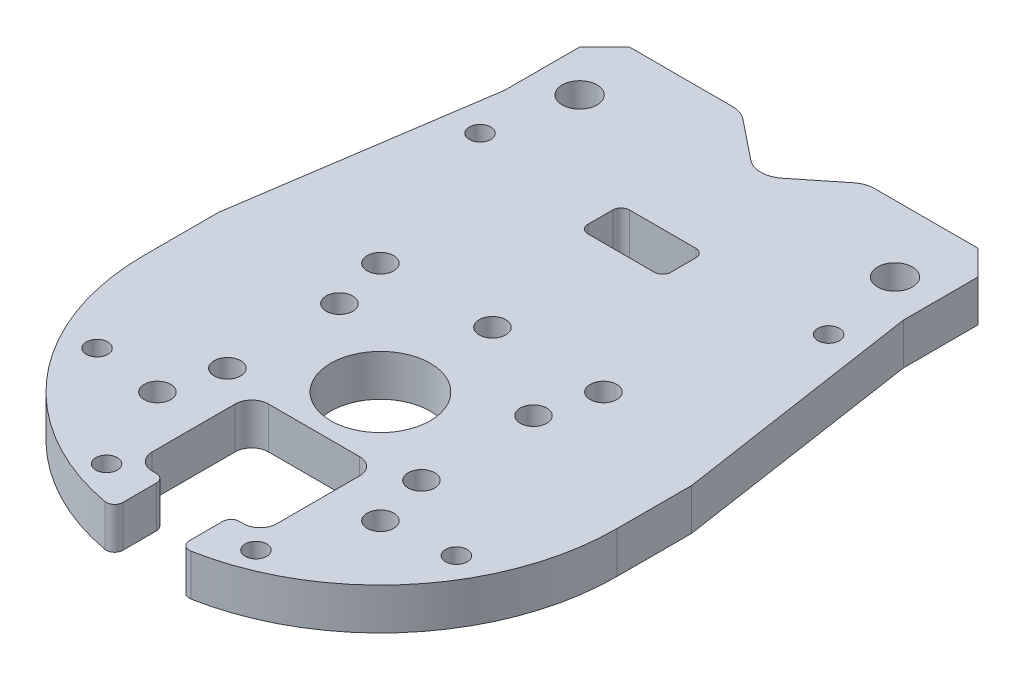
from build123d import *

# Parameters (mm, degrees)
EXTRUDE_1_DEPTH        = 5
HOLE_WIZARD_M5_1_D     = 4.2
HOLE_WIZARD_M5_1_DEPTH = 5
SKETCH_4_R             = 1.6
CUT_EXTRUDE_1_DEPTH    = 10
SKETCH_5_R             = 1.6
CUT_EXTRUDE_2_DEPTH    = 10
SKETCH_6_R             = 6
CUT_EXTRUDE_3_DEPTH    = 10
CHAMFER_1_SIZE         = 2
CUT_EXTRUDE_4_DEPTH    = 6
CHAMFER_2_SIZE         = 3
SKETCH_8_R             = 1.3
CUT_EXTRUDE_5_DEPTH    = 6
SKETCH_9_R             = 1.3
CUT_EXTRUDE_6_DEPTH    = 6
CUT_EXTRUDE_8_DEPTH    = 10
FILLET_1_R             = 3
SKETCH_12_W            = 15
SKETCH_12_H            = 14
CUT_EXTRUDE_9_DEPTH    = 10
FILLET_2_R             = 2
SKETCH_13_W            = 8
SKETCH_13_H            = 6.5
CUT_EXTRUDE_10_DEPTH   = 10
FILLET_3_R             = 1
SKETCH_14_R            = 1.3
CUT_EXTRUDE_11_DEPTH   = 10
SKETCH_15_W            = 10
SKETCH_15_H            = 5
CUT_EXTRUDE_12_DEPTH   = 10
FILLET_4_R             = 1


with BuildPart() as part:
    # 草图1 → 凸台-拉伸1 (new body)
    with BuildSketch(Plane(origin=(0, 0, 0), x_dir=(1, 0, 0), z_dir=(0, 1, 0))):
        with BuildLine():
            Line((-28.5, 0), (28.5, 0))
            Line((28.5, 0), (28.5, -51))
            ThreePointArc((28.5, -51), (0, -79.5), (-28.5, -51))
            Line((-28.5, -51), (-28.5, 0))
        make_face()
    extrude(amount=EXTRUDE_1_DEPTH)

    # M5 螺纹孔1
    with Locations(Plane(origin=(19, 5, 8), x_dir=(0, 0, 1), z_dir=(0, 1, 0))):
        with Locations((0, 0), (0, -38)):
            Hole(HOLE_WIZARD_M5_1_D / 2, depth=HOLE_WIZARD_M5_1_DEPTH)

    # 草图4 → 切除-拉伸1 (cut)
    with BuildSketch(Plane.XZ):
        with Locations((-13.435028843, 64.435028843)):
            Circle(SKETCH_4_R)
        with Locations((13.435028843, 64.435028843)):
            Circle(SKETCH_4_R)
        with Locations((13.435028843, 37.564971157)):
            Circle(SKETCH_4_R)
        with Locations((-13.435028843, 37.564971157)):
            Circle(SKETCH_4_R)
    extrude(amount=-CUT_EXTRUDE_1_DEPTH, mode=Mode.SUBTRACT)

    # 草图5 → 切除-拉伸2 (cut)
    with BuildSketch(Plane.XZ):
        with Locations((0, 64.5)):
            Circle(SKETCH_5_R)
        with Locations((11.691342951, 57.75)):
            Circle(SKETCH_5_R)
        with Locations((11.691342951, 44.25)):
            Circle(SKETCH_5_R)
        with Locations((0, 37.5)):
            Circle(SKETCH_5_R)
        with Locations((-11.691342951, 44.25)):
            Circle(SKETCH_5_R)
        with Locations((-11.691342951, 57.75)):
            Circle(SKETCH_5_R)
    extrude(amount=-CUT_EXTRUDE_2_DEPTH, mode=Mode.SUBTRACT)

    # 草图6 → 切除-拉伸3 (cut)
    with BuildSketch(Plane.XZ):
        with Locations((0, 51)):
            Circle(SKETCH_6_R)
    extrude(amount=-CUT_EXTRUDE_3_DEPTH, mode=Mode.SUBTRACT)

    # 倒角1
    chamfer_1_edges = [part.edges().sort_by_distance(p)[0] for p in [
        (-28.5, 2.5, 0),
        (28.5, 2.5, 0),
    ]]
    chamfer(chamfer_1_edges, length=CHAMFER_1_SIZE)

    # 草图7 → 切除-拉伸4 (cut, through all)
    with BuildSketch(Plane(origin=(0, 5, 0), x_dir=(1, 0, 0), z_dir=(0, 1, 0))):
        Polygon((-24, 0), (-24, -12), (-28.5, -42), (-28.5, -2), (-26.5, 0), align=None)
        Polygon((28.5, -2), (28.5, -42), (24, -12), (24, 0), (26.5, 0), align=None)
    extrude(amount=-CUT_EXTRUDE_4_DEPTH, mode=Mode.SUBTRACT)

    # 倒角2
    chamfer_2_edges = [part.edges().sort_by_distance(p)[0] for p in [
        (-24, 2.5, 0),
        (24, 2.5, 0),
    ]]
    chamfer(chamfer_2_edges, length=CHAMFER_2_SIZE)

    # 草图8 → 切除-拉伸5 (cut, through all)
    with BuildSketch(Plane(origin=(0, 5, 0), x_dir=(1, 0, 0), z_dir=(0, 1, 0))):
        with Locations((-21.650635095, -63.5)):
            Circle(SKETCH_8_R)
        with Locations((21.650635095, -63.5)):
            Circle(SKETCH_8_R)
    extrude(amount=-CUT_EXTRUDE_5_DEPTH, mode=Mode.SUBTRACT)

    # 草图9 → 切除-拉伸6 (cut, through all)
    with BuildSketch(Plane(origin=(0, 5, 0), x_dir=(1, 0, 0), z_dir=(0, 1, 0))):
        with Locations((-21, -18)):
            Circle(SKETCH_9_R)
        with Locations((21, -18)):
            Circle(SKETCH_9_R)
    extrude(amount=-CUT_EXTRUDE_6_DEPTH, mode=Mode.SUBTRACT)

    # 草图11 → 切除-拉伸8 (cut)
    with BuildSketch(Plane(origin=(0, 5, 0), x_dir=(1, 0, 0), z_dir=(0, 1, 0))):
        Polygon((-7.5, 0), (0, -6), (7.5, 0), align=None)
    extrude(amount=-CUT_EXTRUDE_8_DEPTH, mode=Mode.SUBTRACT)

    # 圆角1
    fillet_1_edges = [part.edges().sort_by_distance(p)[0] for p in [
        (-7.5, 2.5, 0),
        (7.5, 2.5, 0),
        (0, 2.5, 6),
    ]]
    fillet(fillet_1_edges, radius=FILLET_1_R)

    # 草图12 → 切除-拉伸9 (cut)
    with BuildSketch(Plane(origin=(0, 5, 0), x_dir=(1, 0, 0), z_dir=(0, 1, 0))):
        with Locations((0, -66)):
            Rectangle(SKETCH_12_W, SKETCH_12_H)
    extrude(amount=-CUT_EXTRUDE_9_DEPTH, mode=Mode.SUBTRACT)

    # 圆角2
    fillet_2_edges = [part.edges().sort_by_distance(p)[0] for p in [
        (-7.5, 2.5, 73),
        (-7.5, 2.5, 59),
        (7.5, 2.5, 59),
        (7.5, 2.5, 73),
    ]]
    fillet(fillet_2_edges, radius=FILLET_2_R)

    # 草图13 → 切除-拉伸10 (cut)
    with BuildSketch(Plane.XZ):
        with Locations((0, 76.25)):
            Rectangle(SKETCH_13_W, SKETCH_13_H)
    extrude(amount=-CUT_EXTRUDE_10_DEPTH, mode=Mode.SUBTRACT)

    # 圆角3
    fillet_3_edges = [part.edges().sort_by_distance(p)[0] for p in [
        (4, 2.5, 73),
        (-4, 2.5, 73),
        (-4, 2.5, 79.217902119),
        (4, 2.5, 79.217902119),
    ]]
    fillet(fillet_3_edges, radius=FILLET_3_R)

    # 草图14 → 切除-拉伸11 (cut)
    with BuildSketch(Plane.XZ):
        with Locations((-9, 75)):
            Circle(SKETCH_14_R)
        with Locations((9, 75)):
            Circle(SKETCH_14_R)
    extrude(amount=-CUT_EXTRUDE_11_DEPTH, mode=Mode.SUBTRACT)

    # 草图15 → 切除-拉伸12 (cut)
    with BuildSketch(Plane(origin=(0, 5, 0), x_dir=(1, 0, 0), z_dir=(0, 1, 0))):
        with Locations((0, -19.5)):
            Rectangle(SKETCH_15_W, SKETCH_15_H)
    extrude(amount=-CUT_EXTRUDE_12_DEPTH, mode=Mode.SUBTRACT)

    # 圆角4
    fillet_4_edges = [part.edges().sort_by_distance(p)[0] for p in [
        (-5, 2.5, 22),
        (-5, 2.5, 17),
        (5, 2.5, 17),
        (5, 2.5, 22),
    ]]
    fillet(fillet_4_edges, radius=FILLET_4_R)


solid = part.part
